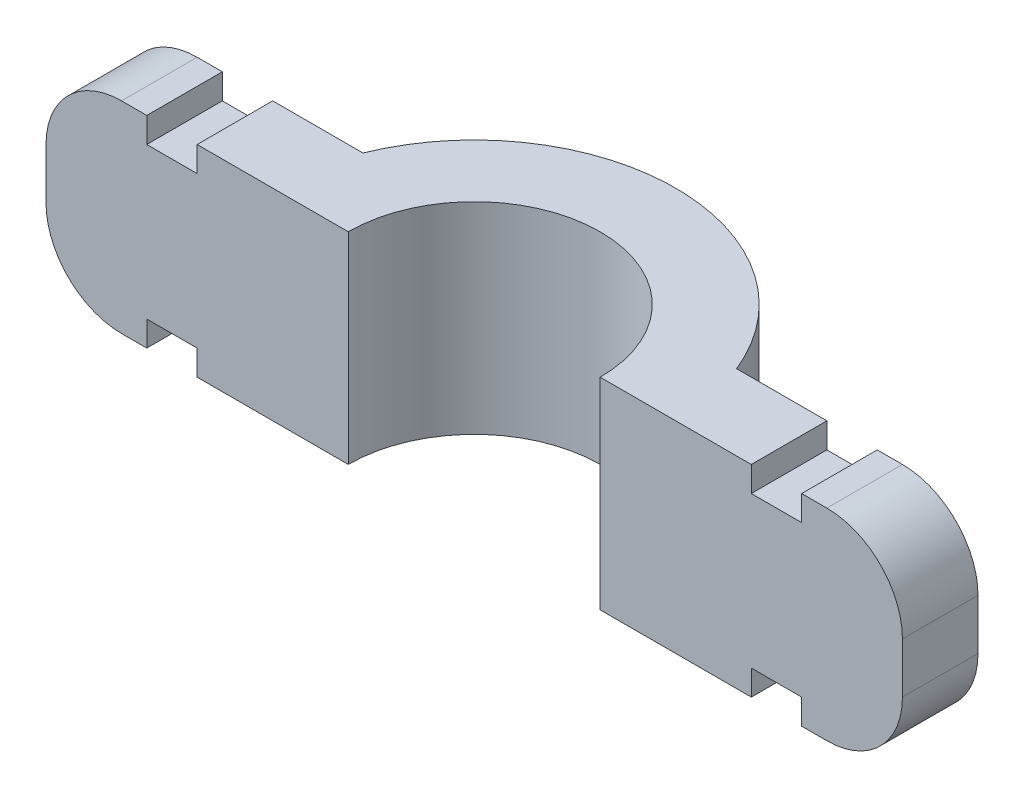
from build123d import *

# Parameters (mm, degrees)
EXTRUDE_1_DEPTH     = 4
SKETCH_2_W          = 2
SKETCH_2_H          = 3
CUT_EXTRUDE_1_DEPTH = 1
FILLET_1_R          = 3


with BuildPart() as part:
    # 草圖1 → 填料-伸長1 (new body, symmetric)
    with BuildSketch(Plane(origin=(0, 0, 0), x_dir=(1, 0, 0), z_dir=(0, 1, 0))):
        with BuildLine():
            Line((-5, 0), (-17, 0))
            Line((-17, 0), (-17, 3))
            Line((-17, 3), (-7.416198487, 3))
            ThreePointArc((-7.416198487, 3), (0, 8), (7.416198487, 3))
            Line((7.416198487, 3), (17, 3))
            Line((17, 3), (17, 0))
            Line((17, 0), (5, 0))
            ThreePointArc((5, 0), (0, 5), (-5, 0))
        make_face()
    extrude(amount=EXTRUDE_1_DEPTH, both=True)

    # 草圖2 → 除料-伸長1 (cut)
    with BuildSketch(Plane(origin=(0, 4, 0), x_dir=(1, 0, 0), z_dir=(0, 1, 0))):
        with Locations((-12, 1.5)):
            Rectangle(SKETCH_2_W, SKETCH_2_H)
        with Locations((12, 1.5)):
            Rectangle(SKETCH_2_W, SKETCH_2_H)
    cut_extrude_1 = extrude(amount=-CUT_EXTRUDE_1_DEPTH, mode=Mode.SUBTRACT)

    # 鏡射1: 除料-伸長1 across plane
    add(cut_extrude_1.mirror(Plane.ZX), mode=Mode.SUBTRACT)

    # 圓角1
    fillet_1_edges = [part.edges().sort_by_distance(p)[0] for p in [
        (17, 4, -1.5),
        (-17, 4, -1.5),
        (-17, -4, -1.5),
        (17, -4, -1.5),
    ]]
    fillet(fillet_1_edges, radius=FILLET_1_R)


solid = part.part
